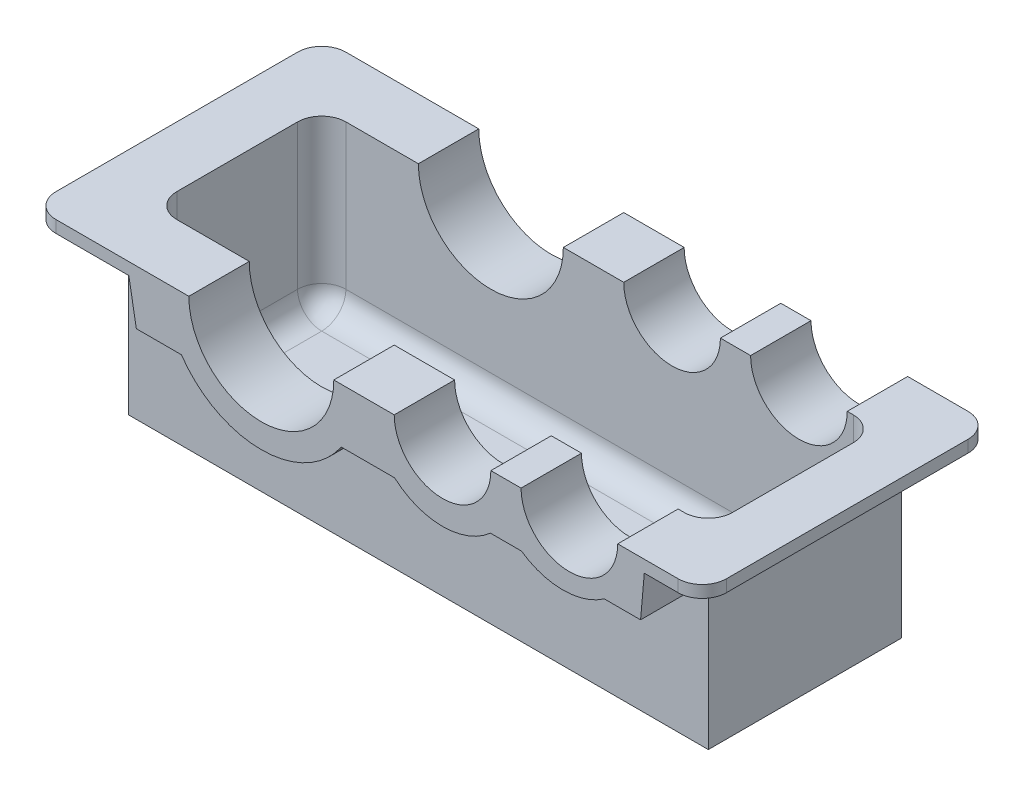
from build123d import *

# Parameters (mm, degrees)
SKETCH1_W               = 160
SKETCH1_H               = 150
BOSS_EXTRUDE1_DEPTH     = 240
SHELL1_T                = -10
SKETCH2_R               = 60
SKETCH2_R_2             = 40
CUT_EXTRUDE1_DEPTH      = 81
CUT_EXTRUDE1_DEPTH_BACK = 81
EXTRUDE_THIN1_DEPTH     = 120
SKETCH4_W               = 460
SKETCH4_H               = 140
CUT_EXTRUDE2_DEPTH      = 100
FILLET1_R               = 20
FILLET2_R               = 20
BOSS_EXTRUDE2_START     = 70
BOSS_EXTRUDE2_DEPTH     = 50
BOSS_EXTRUDE3_START     = -70
BOSS_EXTRUDE3_DEPTH     = 50


with BuildPart() as part:
    # Sketch1 → Boss-Extrude1 (new body, symmetric)
    with BuildSketch(Plane(origin=(0, 0, 0), x_dir=(0, 0, -1), z_dir=(1, 0, 0))):
        with Locations((0, 75)):
            Rectangle(SKETCH1_W, SKETCH1_H)
    extrude(amount=BOSS_EXTRUDE1_DEPTH, both=True)

    # Shell1
    shell1_openings = [part.faces().sort_by_distance(p)[0] for p in [
        (0, 150, 0),
    ]]
    offset(amount=SHELL1_T, openings=shell1_openings, kind=Kind.INTERSECTION)

    # Sketch2 → Cut-Extrude1 (cut, two sides)
    with BuildSketch(Plane.XY) as cut_extrude1_sk:
        with Locations((-90, 150)):
            Circle(SKETCH2_R)
        with Locations((60, 150)):
            Circle(SKETCH2_R_2)
        with Locations((165, 150)):
            Circle(SKETCH2_R_2)
    extrude(amount=CUT_EXTRUDE1_DEPTH, mode=Mode.SUBTRACT)
    extrude(cut_extrude1_sk.sketch, amount=-CUT_EXTRUDE1_DEPTH_BACK, mode=Mode.SUBTRACT)

    # Sketch3 → Extrude-Thin1 (add, symmetric)
    with BuildSketch(Plane.XY):
        with BuildLine():
            Line((275, 150), (205, 150))
            ThreePointArc((205, 150), (165, 110), (125, 150))
            Line((125, 150), (100, 150))
            ThreePointArc((100, 150), (60, 110), (20, 150))
            Line((20, 150), (-30, 150))
            ThreePointArc((-30, 150), (-90, 90), (-150, 150))
            Line((-150, 150), (-280, 150))
            Line((-280, 150), (-280, 140))
            Line((-280, 140), (-159.282032303, 140))
            ThreePointArc((-159.282032303, 140), (-90, 80), (-20.717967697, 140))
            Line((-20.717967697, 140), (11.010205144, 140))
            ThreePointArc((11.010205144, 140), (60, 100), (108.989794856, 140))
            Line((108.989794856, 140), (116.010205144, 140))
            ThreePointArc((116.010205144, 140), (165, 100), (213.989794856, 140))
            Line((213.989794856, 140), (275, 140))
            Line((275, 140), (275, 150))
        make_face()
    extrude(amount=EXTRUDE_THIN1_DEPTH, both=True)

    # Sketch4 → Cut-Extrude2 (cut)
    with BuildSketch(Plane(origin=(0, 150, 0), x_dir=(1, 0, 0), z_dir=(0, 1, 0))):
        Rectangle(SKETCH4_W, SKETCH4_H)
    extrude(amount=-CUT_EXTRUDE2_DEPTH, mode=Mode.SUBTRACT)

    # Fillet1
    fillet1_edges = [part.edges().sort_by_distance(p)[0] for p in [
        (275, 145, 120),
        (-280, 145, 120),
        (-280, 145, -120),
        (275, 145, -120),
    ]]
    fillet(fillet1_edges, radius=FILLET1_R)

    # Fillet2
    fillet2_edges = [part.edges().sort_by_distance(p)[0] for p in [
        (-230, 10, 0),
        (0, 10, 70),
        (-230, 80, -70),
        (0, 10, -70),
        (230, 10, 0),
        (230, 80, -70),
        (-230, 80, 70),
        (230, 80, 70),
    ]]
    fillet(fillet2_edges, radius=FILLET2_R)

    # Sketch5 → Boss-Extrude2 (add)
    with BuildSketch(Plane.XY.offset(BOSS_EXTRUDE2_START)):
        with BuildLine():
            Line((226.994897428, 140), (223.932794204, 105))
            Line((223.932794204, 105), (193.932794204, 105))
            ThreePointArc((193.932794204, 105), (159.623262269, 94.22251536), (125.313730334, 105))
            Line((125.313730334, 105), (99.686269666, 105))
            ThreePointArc((99.686269666, 105), (60, 90), (20.313730334, 105))
            Line((20.313730334, 105), (-23.856217223, 105))
            ThreePointArc((-23.856217223, 105), (-90, 70), (-156.143782777, 105))
            Line((-156.143782777, 105), (-193.469571827, 105))
            Line((-193.469571827, 105), (-199.641016151, 140))
            Line((-199.641016151, 140), (-199.641016151, 145.622193668))
            Line((-199.641016151, 145.622193668), (-149.84007697, 145.622193668))
            ThreePointArc((-149.84007697, 145.622193668), (-90, 90), (-30.15992303, 145.622193668))
            Line((-30.15992303, 145.622193668), (20.240286574, 145.622193668))
            ThreePointArc((20.240286574, 145.622193668), (60, 110), (99.759713426, 145.622193668))
            Line((99.759713426, 145.622193668), (125.240286574, 145.622193668))
            ThreePointArc((125.240286574, 145.622193668), (165, 110), (204.759713426, 145.622193668))
            Line((204.759713426, 145.622193668), (226.994897428, 145.622193668))
            Line((226.994897428, 145.622193668), (226.994897428, 140))
        make_face()
    extrude(amount=BOSS_EXTRUDE2_DEPTH)

    # Sketch5_3 → Boss-Extrude3 (add)
    with BuildSketch(Plane.XY.offset(BOSS_EXTRUDE3_START)):
        with BuildLine():
            Line((226.994897428, 140), (223.932794204, 105))
            Line((223.932794204, 105), (193.932794204, 105))
            ThreePointArc((193.932794204, 105), (159.623262269, 94.22251536), (125.313730334, 105))
            Line((125.313730334, 105), (99.686269666, 105))
            ThreePointArc((99.686269666, 105), (60, 90), (20.313730334, 105))
            Line((20.313730334, 105), (-23.856217223, 105))
            ThreePointArc((-23.856217223, 105), (-90, 70), (-156.143782777, 105))
            Line((-156.143782777, 105), (-193.469571827, 105))
            Line((-193.469571827, 105), (-199.641016151, 140))
            Line((-199.641016151, 140), (-199.641016151, 145.622193668))
            Line((-199.641016151, 145.622193668), (-149.84007697, 145.622193668))
            ThreePointArc((-149.84007697, 145.622193668), (-90, 90), (-30.15992303, 145.622193668))
            Line((-30.15992303, 145.622193668), (20.240286574, 145.622193668))
            ThreePointArc((20.240286574, 145.622193668), (60, 110), (99.759713426, 145.622193668))
            Line((99.759713426, 145.622193668), (125.240286574, 145.622193668))
            ThreePointArc((125.240286574, 145.622193668), (165, 110), (204.759713426, 145.622193668))
            Line((204.759713426, 145.622193668), (226.994897428, 145.622193668))
            Line((226.994897428, 145.622193668), (226.994897428, 140))
        make_face()
    extrude(amount=-BOSS_EXTRUDE3_DEPTH)


solid = part.part
